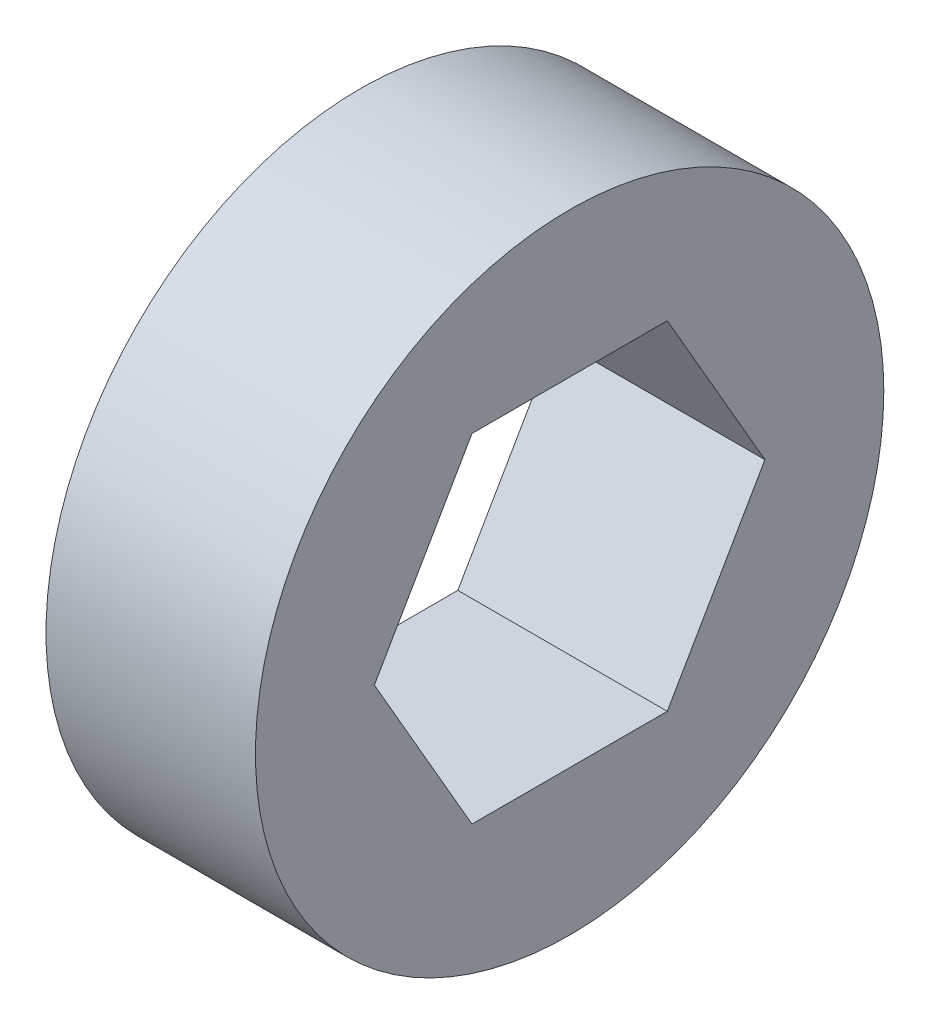
from build123d import *

# Parameters (mm, degrees)
SKETCH1_R           = 4.7625
BOSS_EXTRUDE1_DEPTH = 3.175


with BuildPart() as part:
    # Sketch1 → Boss-Extrude1 (new body)
    with BuildSketch(Plane(origin=(0, 0, 0), x_dir=(0, 0, -1), z_dir=(1, 0, 0))):
        Circle(SKETCH1_R)
        Polygon((1.480037388, 2.563499953), (-1.480037388, 2.563499953), (-2.960074776, 0), (-1.480037388, -2.563499953), (1.480037388, -2.563499953), (2.960074776, 0), align=None, mode=Mode.SUBTRACT)
    extrude(amount=BOSS_EXTRUDE1_DEPTH)


solid = part.part
